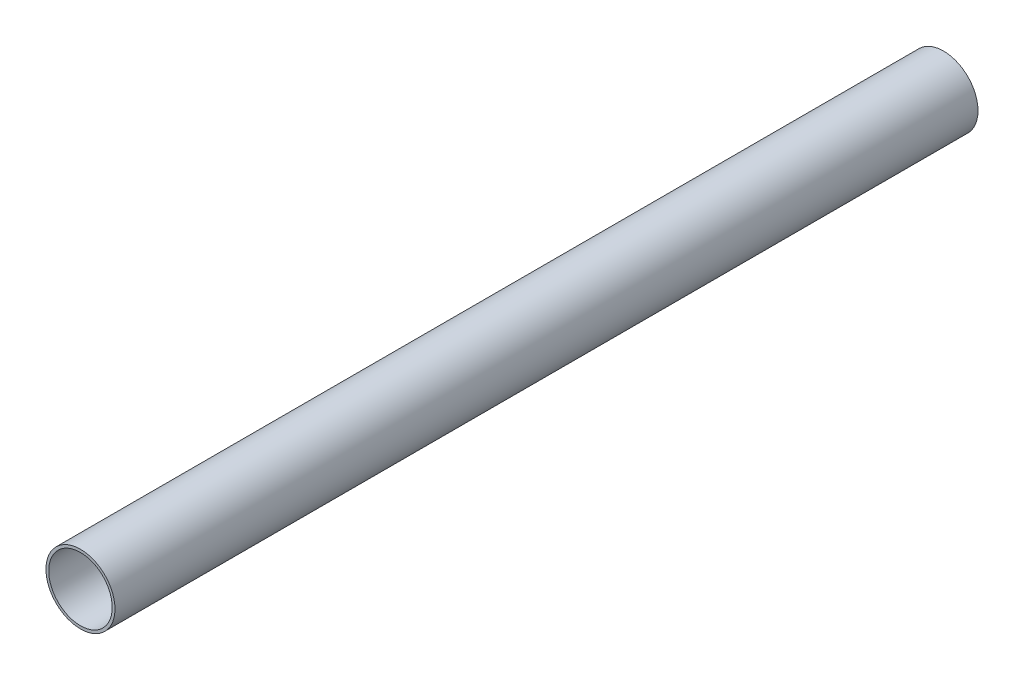
from build123d import *

# Parameters (mm, degrees)
SKETCH_1_R      = 20
SKETCH_1_R_2    = 18.4
EXTRUDE_1_DEPTH = 500


with BuildPart() as part:
    # 스케치1 → 돌출-얇게1 (new body)
    with BuildSketch(Plane.XY):
        Circle(SKETCH_1_R)
        Circle(SKETCH_1_R_2, mode=Mode.SUBTRACT)
    extrude(amount=EXTRUDE_1_DEPTH)


solid = part.part
